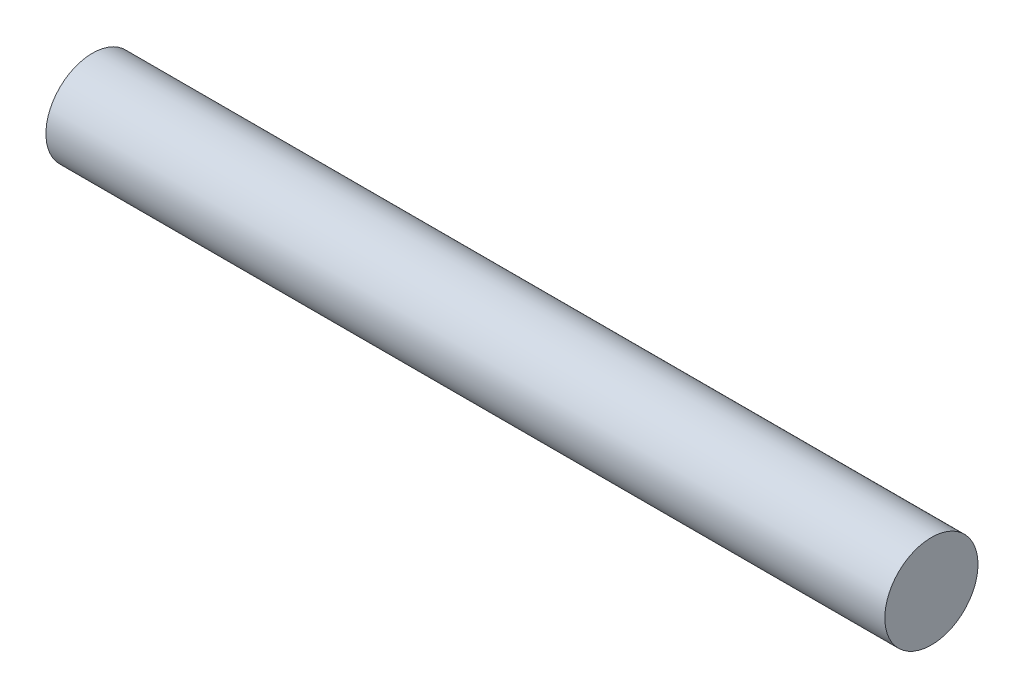
from build123d import *

# Parameters (mm, degrees)
SKETCH1_R           = 9.525
BOSS_EXTRUDE1_DEPTH = 171.45


with BuildPart() as part:
    # Sketch1 → Boss-Extrude1 (new body)
    with BuildSketch(Plane(origin=(0, 0, 0), x_dir=(0, 0, -1), z_dir=(1, 0, 0))):
        Circle(SKETCH1_R)
    extrude(amount=BOSS_EXTRUDE1_DEPTH)


solid = part.part
